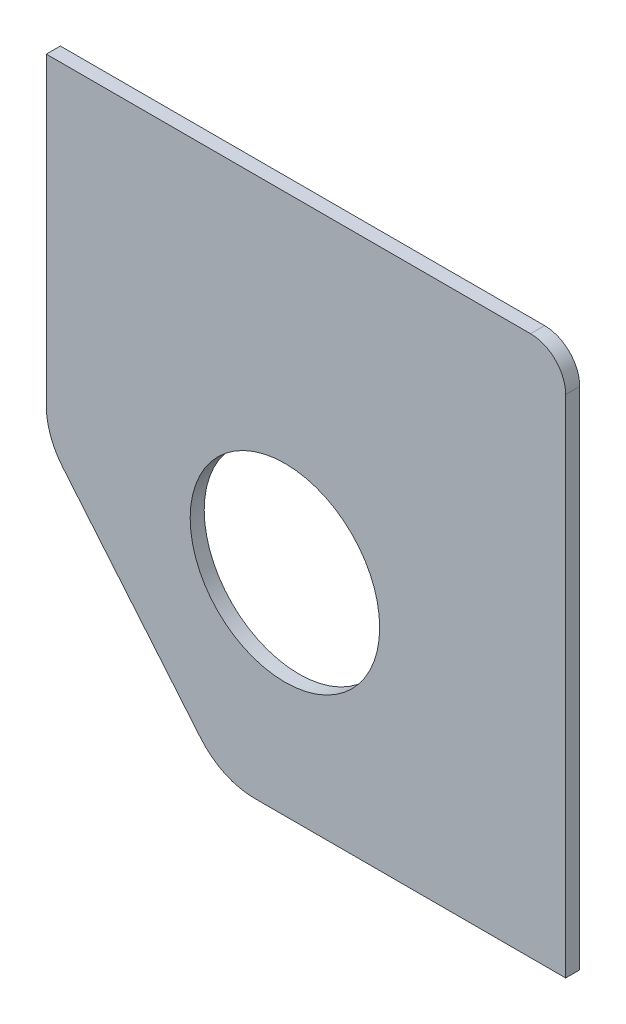
from build123d import *

# Parameters (mm, degrees)
ESBO_O1_W                  = 74
ESBO_O1_H                  = 77
RESSALTO_EXTRUS_O1_DEPTH   = 2
ESBO_O2_R                  = 13.5
CORTE_EXTRUS_O2_DEPTH      = 2
CORTE_EXTRUS_O4_DEPTH      = 1
CORTE_EXTRUS_O4_DEPTH_BACK = 3
FILETE1_R                  = 5
FILETE3_R                  = 10
FILETE4_R                  = 10


with BuildPart() as part:
    # Esboço1 → Ressalto-extrusão1 (new body)
    with BuildSketch(Plane.XY):
        with Locations((-2.694889042, -9.645522388)):
            Rectangle(ESBO_O1_W, ESBO_O1_H)
    extrude(amount=RESSALTO_EXTRUS_O1_DEPTH)

    # Esboço2 → Corte-extrusão2 (cut)
    with BuildSketch(Plane.XY.offset(2)):
        with Locations((-5.694889042, -18.145522388)):
            Circle(ESBO_O2_R)
    extrude(amount=-CORTE_EXTRUS_O2_DEPTH, mode=Mode.SUBTRACT)

    # Esboço3 → Corte-extrusão4 (cut, two sides)
    with BuildSketch(Plane.XY.offset(2)) as corte_extrus_o4_sk:
        Polygon((-162.954500024, 129.766010791), (-39.694889042, -18.145522388), (-14.694889042, -48.145522388), (108.564721941, -196.057055567), (-187.258344417, -442.576277532), (-458.777566382, -116.753211174), align=None)
    extrude(amount=CORTE_EXTRUS_O4_DEPTH, mode=Mode.SUBTRACT)
    extrude(corte_extrus_o4_sk.sketch, amount=-CORTE_EXTRUS_O4_DEPTH_BACK, mode=Mode.SUBTRACT)

    # Filete1
    filete1_edges = [part.edges().sort_by_distance(p)[0] for p in [
        (34.305110958, 28.854477612, 1),
    ]]
    fillet(filete1_edges, radius=FILETE1_R)

    # Filete3
    filete3_edges = [part.edges().sort_by_distance(p)[0] for p in [
        (-39.694889042, -18.145522388, 1),
    ]]
    fillet(filete3_edges, radius=FILETE3_R)

    # Filete4
    filete4_edges = [part.edges().sort_by_distance(p)[0] for p in [
        (-14.694889042, -48.145522388, 1),
    ]]
    fillet(filete4_edges, radius=FILETE4_R)


solid = part.part
